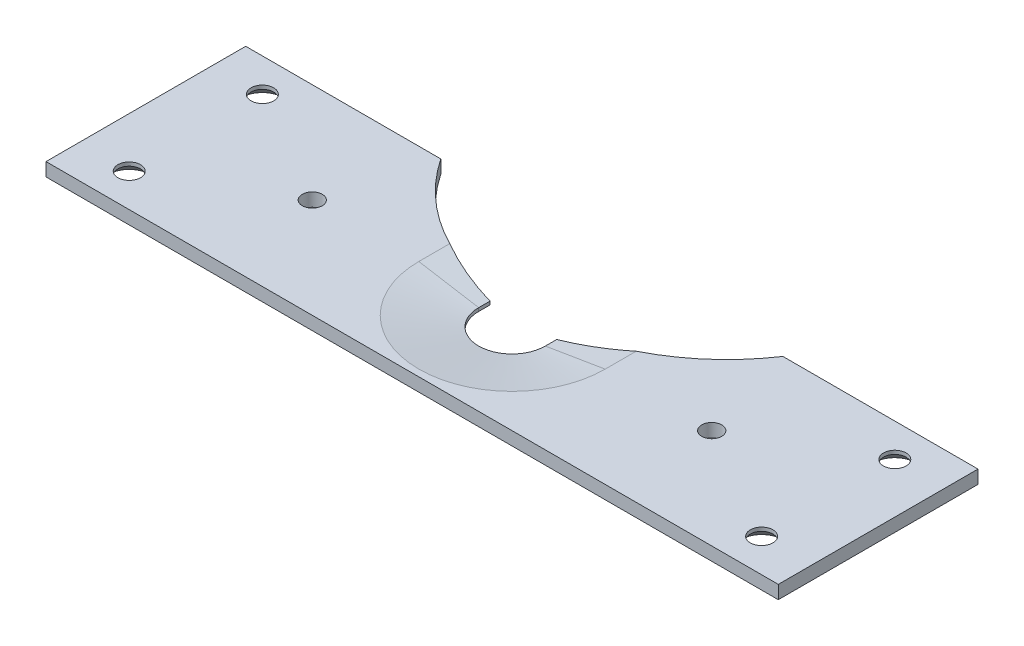
from build123d import *

# Parameters (mm, degrees)
SKETCH1_W                                    = 110
SKETCH1_H                                    = 30
EXTRUDE1_DEPTH                               = 2
CUT_EXTRUDE1_DEPTH                           = 3
CHAMFER1_SIZE                                = 9
CHAMFER1_SIZE2                               = 1.5
CSK_FOR_M3_COUNTERSUNK_RAISED_HEAD_S_2_COUNT = 2
CSK_FOR_M3_COUNTERSUNK_RAISED_HEAD_S_2_PITCH = 95
CSK_FOR_M3_COUNTERSUNK_RAISED_HEAD_S_3_COUNT = 2
CSK_FOR_M3_COUNTERSUNK_RAISED_HEAD_S_3_PITCH = 97.082439195
CSK_FOR_M3_COUNTERSUNK_RAISED_HEAD_S_4_COUNT = 2
CSK_FOR_M3_COUNTERSUNK_RAISED_HEAD_S_4_PITCH = 20
M3_TAPPED_HOLE1_D                            = 3
SKETCH13_R                                   = 30.96323942
CUT_EXTRUDE2_DEPTH                           = 3


with BuildPart() as part:
    # Sketch1 → Extrude1 (new body)
    with BuildSketch(Plane(origin=(0, 0, 0), x_dir=(1, 0, 0), z_dir=(0, 1, 0))):
        Rectangle(SKETCH1_W, SKETCH1_H)
    extrude(amount=EXTRUDE1_DEPTH)

    # Sketch2 → Cut-Extrude1 (cut, through all)
    with BuildSketch(Plane(origin=(0, 2, 0), x_dir=(-1, 0, 0), z_dir=(0, 1, 0))):
        with BuildLine():
            Line((5, 0), (5, -15))
            Line((5, -15), (-5, -15))
            Line((-5, -15), (-5, 0))
            ThreePointArc((-5, 0), (0, 5), (5, 0))
        make_face()
    extrude(amount=-CUT_EXTRUDE1_DEPTH, mode=Mode.SUBTRACT)

    # Chamfer1
    chamfer1_edges = [part.edges().sort_by_distance(p)[0] for p in [
        (0, 2, 5),
        (5, 2, -7.5),
        (-5, 2, -7.5),
    ]]
    chamfer1_side = [part.faces().sort_by_distance(p)[0] for p in [
        (-53.859824575, 2, 0),
    ]]
    chamfer(chamfer1_edges, length=CHAMFER1_SIZE, length2=CHAMFER1_SIZE2, reference=chamfer1_side[0])

    # Sketch8 → CSK for M3 Countersunk Raised Head Screw1 (revolve, cut)
    with BuildSketch(Plane(origin=(47.5, 0, -10), x_dir=(0, 0, -1), z_dir=(1, 0, 0))):
        Polygon((0, 0), (0, 2), (1.7, 2), (1.7, 1.45), (3.15, 0), align=None)
    csk_for_m3_countersunk_raised_head_screw = revolve(axis=Axis((47.5, -6.35, -10), (0, 1, 0)), mode=Mode.SUBTRACT)

    # CSK for M3 Countersunk Raised Head S 2: CSK for M3 Countersunk Raised Head Screw1 ×2
    with Locations(*[(-i * CSK_FOR_M3_COUNTERSUNK_RAISED_HEAD_S_2_PITCH, 0, 0) for i in range(1, CSK_FOR_M3_COUNTERSUNK_RAISED_HEAD_S_2_COUNT)]):
        add(csk_for_m3_countersunk_raised_head_screw, mode=Mode.SUBTRACT)

    # CSK for M3 Countersunk Raised Head S 3: CSK for M3 Countersunk Raised Head Screw1 ×2
    with Locations(*[Vector(-0.978549785, 0, 0.206010481) * (i * CSK_FOR_M3_COUNTERSUNK_RAISED_HEAD_S_3_PITCH) for i in range(1, CSK_FOR_M3_COUNTERSUNK_RAISED_HEAD_S_3_COUNT)]):
        add(csk_for_m3_countersunk_raised_head_screw, mode=Mode.SUBTRACT)

    # CSK for M3 Countersunk Raised Head S 4: CSK for M3 Countersunk Raised Head Screw1 ×2
    with Locations(*[(0, 0, i * CSK_FOR_M3_COUNTERSUNK_RAISED_HEAD_S_4_PITCH) for i in range(1, CSK_FOR_M3_COUNTERSUNK_RAISED_HEAD_S_4_COUNT)]):
        add(csk_for_m3_countersunk_raised_head_screw, mode=Mode.SUBTRACT)

    # M3 Tapped Hole1 (through all)
    with Locations(Plane(origin=(0, 2, 0), x_dir=(-1, 0, 0), z_dir=(0, 1, 0))):
        with Locations((-30, 0), (30, 0)):
            Hole(M3_TAPPED_HOLE1_D / 2)

    # Sketch13 → Cut-Extrude2 (cut, through all)
    with BuildSketch(Plane.XZ):
        with Locations((0, -32.270962356)):
            Circle(SKETCH13_R)
    extrude(amount=-CUT_EXTRUDE2_DEPTH, mode=Mode.SUBTRACT)


solid = part.part
